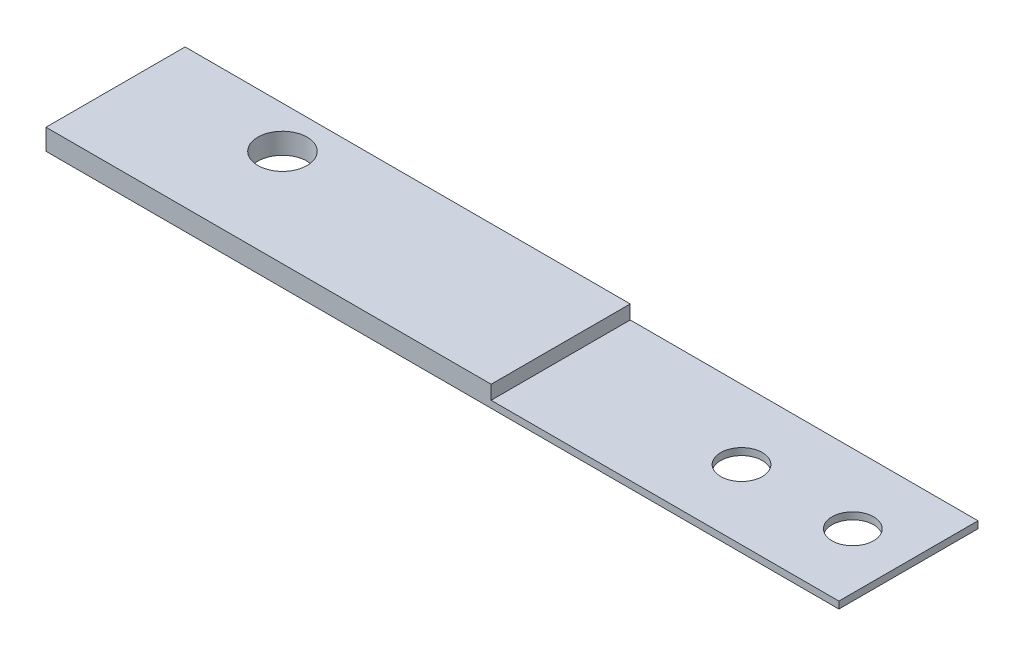
from build123d import *

# Parameters (mm, degrees)
SKETCH1_W               = 72.39
SKETCH1_H               = 12.7
BOSS_EXTRUDE1_DEPTH     = 0.635
SKETCH2_W               = 40.64
SKETCH2_H               = 12.7
BOSS_EXTRUDE2_DEPTH     = 1.27
F_6_CLEARANCE_HOLE1_D   = 3.7973
F_8_CLEARANCE_HOLE1_D   = 4.4958
CUT_EXTRUDE6_DEPTH      = 1
CUT_EXTRUDE6_DEPTH_BACK = 10.16


with BuildPart() as part:
    # Sketch1 → Boss-Extrude1 (new body)
    with BuildSketch(Plane(origin=(0, 0, 0), x_dir=(1, 0, 0), z_dir=(0, 1, 0))):
        with Locations((36.195, -6.35)):
            Rectangle(SKETCH1_W, SKETCH1_H)
    extrude(amount=BOSS_EXTRUDE1_DEPTH)

    # Sketch2 → Boss-Extrude2 (add)
    with BuildSketch(Plane(origin=(0, 0.635, 0), x_dir=(1, 0, 0), z_dir=(0, 1, 0))):
        with Locations((20.32, -6.35)):
            Rectangle(SKETCH2_W, SKETCH2_H)
    extrude(amount=BOSS_EXTRUDE2_DEPTH)

    # #6 Clearance Hole1 (through all)
    with Locations(Plane(origin=(0, 0, 0), x_dir=(-1, 0, 0), z_dir=(0, -1, 0))):
        with Locations((-67.31, -6.35), (-57.15, -6.35)):
            Hole(F_6_CLEARANCE_HOLE1_D / 2)

    # #8 Clearance Hole1 (through all)
    with Locations(Plane(origin=(0, 0, 0), x_dir=(-1, 0, 0), z_dir=(0, -1, 0))):
        with Locations((-12.7, -3.81)):
            Hole(F_8_CLEARANCE_HOLE1_D / 2)

    # Sketch9 → Cut-Extrude6 (cut, two sides)
    with BuildSketch(Plane.ZY) as cut_extrude6_sk:
        Polygon((1.563293937, 0.508), (1.27, 0), (1.856587873, 0), align=None)
        Polygon((2.14988181, 0.508), (1.856587873, 0), (2.443175747, 0), align=None)
        Polygon((0.87988181, 0.508), (0.586587873, 0), (1.173175747, 0), align=None)
        Polygon((0.293293937, 0.508), (0, 0), (0.586587873, 0), align=None)
        Polygon((2.833293937, 0.508), (2.54, 0), (3.126587873, 0), align=None)
        Polygon((3.41988181, 0.508), (3.126587873, 0), (3.713175747, 0), align=None)
        Polygon((4.103293937, 0.508), (3.81, 0), (4.396587873, 0), align=None)
        Polygon((4.68988181, 0.508), (4.396587873, 0), (4.983175747, 0), align=None)
        Polygon((5.373293937, 0.508), (5.08, 0), (5.666587873, 0), align=None)
        Polygon((5.95988181, 0.508), (5.666587873, 0), (6.253175747, 0), align=None)
        Polygon((6.643293937, 0.508), (6.35, 0), (6.936587873, 0), align=None)
        Polygon((7.22988181, 0.508), (6.936587873, 0), (7.523175747, 0), align=None)
        Polygon((7.913293937, 0.508), (7.62, 0), (8.206587873, 0), align=None)
        Polygon((8.49988181, 0.508), (8.206587873, 0), (8.793175747, 0), align=None)
        Polygon((9.183293937, 0.508), (8.89, 0), (9.476587873, 0), align=None)
        Polygon((9.76988181, 0.508), (9.476587873, 0), (10.063175747, 0), align=None)
        Polygon((10.453293937, 0.508), (10.16, 0), (10.746587873, 0), align=None)
        Polygon((11.03988181, 0.508), (10.746587873, 0), (11.333175747, 0), align=None)
        Polygon((11.723293937, 0.508), (11.43, 0), (12.016587873, 0), align=None)
        Polygon((12.30988181, 0.508), (12.016587873, 0), (12.603175747, 0), align=None)
    extrude(amount=CUT_EXTRUDE6_DEPTH, mode=Mode.SUBTRACT)
    extrude(cut_extrude6_sk.sketch, amount=-CUT_EXTRUDE6_DEPTH_BACK, mode=Mode.SUBTRACT)


solid = part.part
